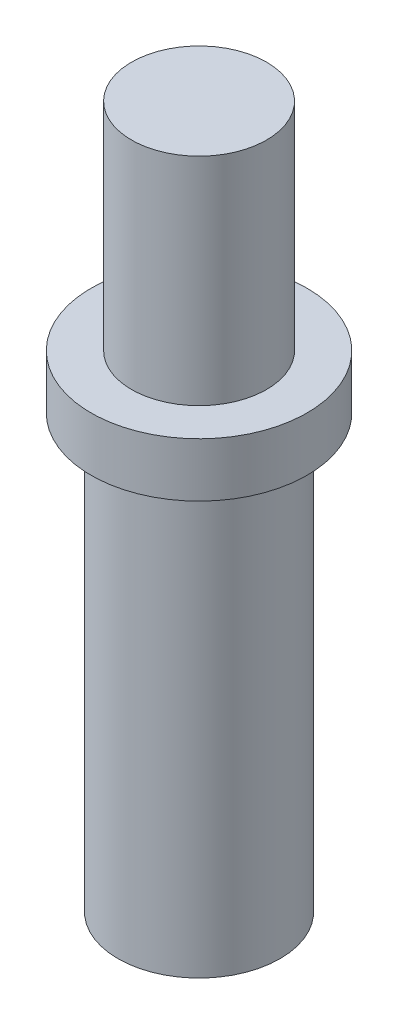
from build123d import *


with BuildPart() as part:
    # Esquisse1 → Révolution1 (revolve)
    with BuildSketch(Plane.XY):
        Polygon((4, 27.229697987), (4, 29.229697987), (2.5, 29.229697987), (2.5, 37.229697987), (0, 37.229697987), (0, 26.229697987), (2, 26.229697987), (2, 11.229697987), (3, 11.229697987), (3, 27.229697987), align=None)
    revolve(axis=Axis((0, 0, 0), (0, 1, 0)))


solid = part.part
